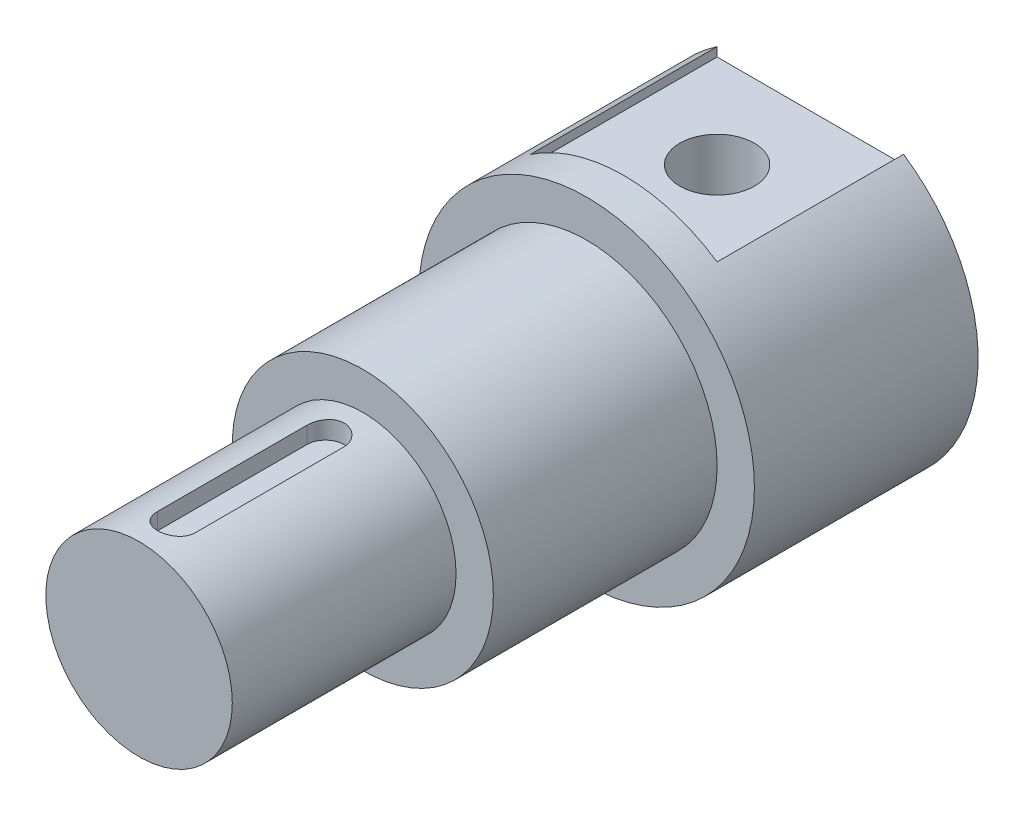
from build123d import *

# Parameters (mm, degrees)
CROQUIS1_R              = 18
SALIENTE_EXTRUIR1_DEPTH = 24
CROQUIS2_R              = 14
SALIENTE_EXTRUIR2_DEPTH = 24
CROQUIS3_R              = 10
SALIENTE_EXTRUIR3_DEPTH = 24
CORTAR_EXTRUIR1_DEPTH   = 2
CORTAR_EXTRUIR2_DEPTH   = 2
CROQUIS6_W              = 20
CROQUIS6_H              = 20
CORTAR_EXTRUIR3_DEPTH   = 4
CROQUIS7_W              = 20
CROQUIS7_H              = 20
CORTAR_EXTRUIR4_DEPTH   = 4
CROQUIS8_R              = 4
CORTAR_EXTRUIR5_DEPTH   = 33


with BuildPart() as part:
    # Croquis1 → Saliente-Extruir1 (new body)
    with BuildSketch(Plane.XY):
        Circle(CROQUIS1_R)
    extrude(amount=SALIENTE_EXTRUIR1_DEPTH)

    # Croquis2 → Saliente-Extruir2 (add)
    with BuildSketch(Plane.XY.offset(24)):
        Circle(CROQUIS2_R)
    extrude(amount=SALIENTE_EXTRUIR2_DEPTH)

    # Croquis3 → Saliente-Extruir3 (add)
    with BuildSketch(Plane.XY.offset(48)):
        Circle(CROQUIS3_R)
    extrude(amount=SALIENTE_EXTRUIR3_DEPTH)

    # Croquis4 → Cortar-Extruir1 (cut)
    with BuildSketch(Plane(origin=(0, 10, 0), x_dir=(1, 0, 0), z_dir=(0, 1, 0))):
        with BuildLine():
            Line((2, -52), (2, -68))
            ThreePointArc((2, -68), (0, -70), (-2, -68))
            Line((-2, -68), (-2, -52))
            ThreePointArc((-2, -52), (0, -50), (2, -52))
        make_face()
    extrude(amount=-CORTAR_EXTRUIR1_DEPTH, mode=Mode.SUBTRACT)

    # Croquis5 → Cortar-Extruir2 (cut)
    with BuildSketch(Plane(origin=(0, -10, 0), x_dir=(1, 0, 0), z_dir=(0, 1, 0))):
        with BuildLine():
            Line((-2, -68), (-2, -52))
            ThreePointArc((-2, -52), (0, -50), (2, -52))
            Line((2, -52), (2, -68))
            ThreePointArc((2, -68), (0, -70), (-2, -68))
        make_face()
    extrude(amount=CORTAR_EXTRUIR2_DEPTH, mode=Mode.SUBTRACT)

    # Croquis6 → Cortar-Extruir3 (cut)
    with BuildSketch(Plane(origin=(0, 18, 0), x_dir=(1, 0, 0), z_dir=(0, 1, 0))):
        with Locations((0, -10)):
            Rectangle(CROQUIS6_W, CROQUIS6_H)
    extrude(amount=-CORTAR_EXTRUIR3_DEPTH, mode=Mode.SUBTRACT)

    # Croquis7 → Cortar-Extruir4 (cut)
    with BuildSketch(Plane(origin=(0, -18, 0), x_dir=(1, 0, 0), z_dir=(0, 1, 0))):
        with Locations((0, -10)):
            Rectangle(CROQUIS7_W, CROQUIS7_H)
    extrude(amount=CORTAR_EXTRUIR4_DEPTH, mode=Mode.SUBTRACT)

    # Croquis8 → Cortar-Extruir5 (cut, through all)
    with BuildSketch(Plane.XZ.offset(14)):
        with Locations((0, 10)):
            Circle(CROQUIS8_R)
    extrude(amount=-CORTAR_EXTRUIR5_DEPTH, mode=Mode.SUBTRACT)


solid = part.part
